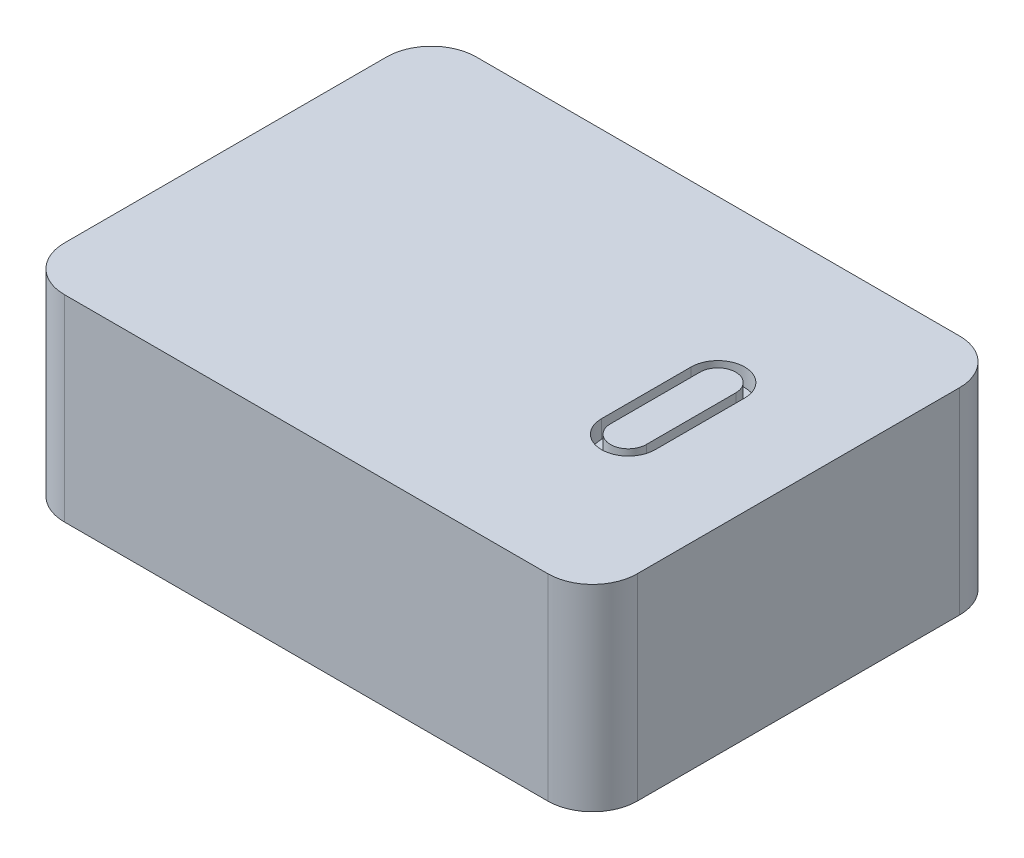
from build123d import *

# Parameters (mm, degrees)
SKETCH_1_W          = 64
SKETCH_1_H          = 46
EXTRUDE_1_DEPTH     = 22
FILLET_1_R          = 5
CUT_EXTRUDE_1_DEPTH = 2


with BuildPart() as part:
    # 草图1 → 凸台-拉伸1 (new body)
    with BuildSketch(Plane(origin=(0, 0, 0), x_dir=(1, 0, 0), z_dir=(0, 1, 0))):
        Rectangle(SKETCH_1_W, SKETCH_1_H)
    extrude(amount=EXTRUDE_1_DEPTH)

    # 圆角1
    fillet_1_edges = [part.edges().sort_by_distance(p)[0] for p in [
        (32, 11, 23),
        (-32, 11, 23),
        (-32, 11, -23),
        (32, 11, -23),
    ]]
    fillet(fillet_1_edges, radius=FILLET_1_R)

    # 草图2 → 切除-拉伸1 (cut)
    with BuildSketch(Plane(origin=(0, 22, 0), x_dir=(1, 0, 0), z_dir=(0, 1, 0))):
        with BuildLine():
            Line((15, -5), (15, 5))
            ThreePointArc((15, 5), (18, 8), (21, 5))
            Line((21, 5), (21, -5))
            ThreePointArc((21, -5), (18, -8), (15, -5))
        make_face()
        with BuildLine():
            Line((16, -5), (16, 5))
            ThreePointArc((16, 5), (18, 7), (20, 5))
            Line((20, 5), (20, -5))
            ThreePointArc((20, -5), (18, -7), (16, -5))
        make_face(mode=Mode.SUBTRACT)
    extrude(amount=-CUT_EXTRUDE_1_DEPTH, mode=Mode.SUBTRACT)


solid = part.part
